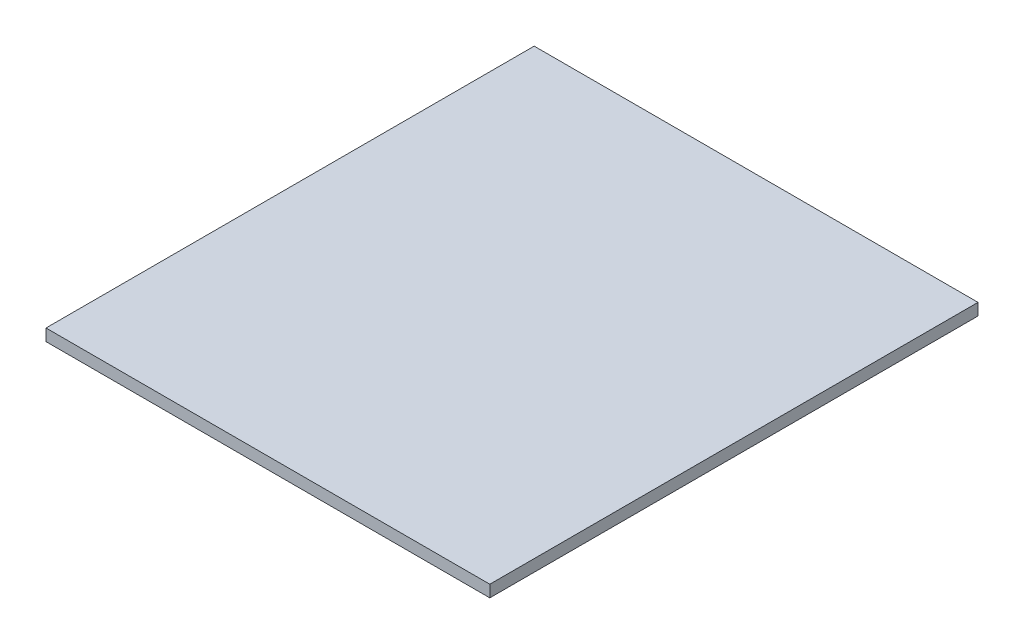
from build123d import *

# Parameters (mm, degrees)
SKETCH1_W           = 150
SKETCH1_H           = 165
BOSS_EXTRUDE1_DEPTH = 4


with BuildPart() as part:
    # Sketch1 → Boss-Extrude1 (new body)
    with BuildSketch(Plane(origin=(0, 0, 0), x_dir=(1, 0, 0), z_dir=(0, 1, 0))):
        with Locations((75, 82.5)):
            Rectangle(SKETCH1_W, SKETCH1_H)
    extrude(amount=BOSS_EXTRUDE1_DEPTH)


solid = part.part
